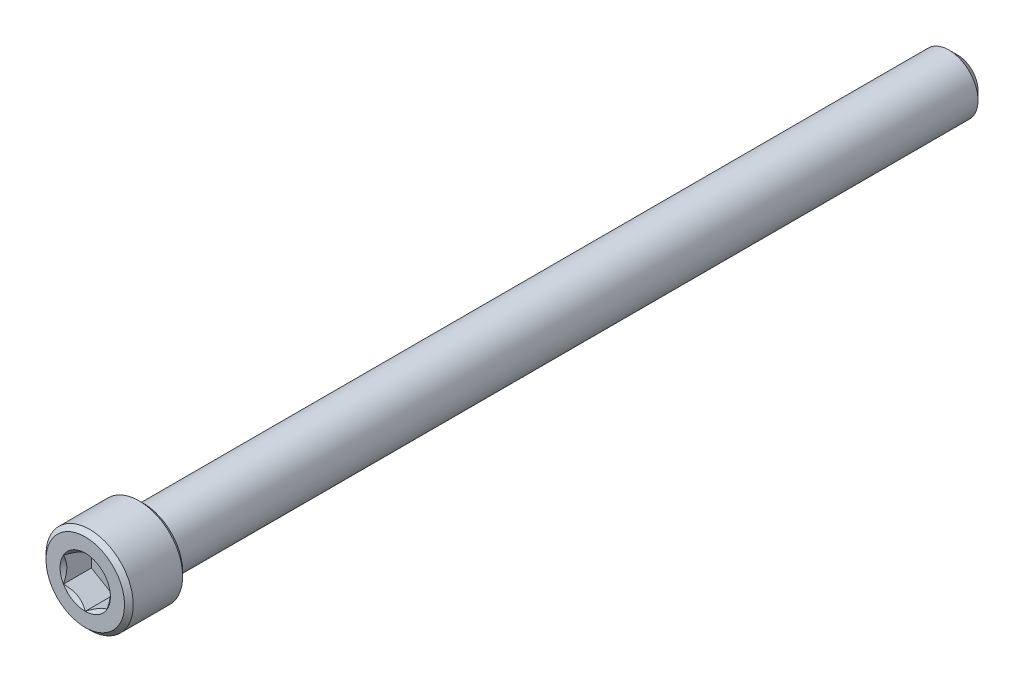
from build123d import *

# Parameters (mm, degrees)
CUT_EXTRUDE1_DEPTH = 3.048
SKETCH5_R          = 2.749630657
CUT_EXTRUDE2_DEPTH = 3.048
CUT_EXTRUDE2_DRAFT = -45
CHAMFER1_SIZE      = 0.47625


with BuildPart() as part:
    # Sketch3 → Revolve1 (revolve)
    with BuildSketch(Plane(origin=(0, 0, 0), x_dir=(0, 0, -1), z_dir=(1, 0, 0))):
        Polygon((-47.625, 4.7625), (-47.625, 2.38125), (-44.577, 2.38125), (-44.577, 0), (47.625, 0), (47.625, 2.2225), (46.6725, 3.175), (-41.275, 3.175), (-41.275, 4.7625), align=None)
    revolve(axis=Axis((0, 0, 47.625), (0, 0, -1)))

    # Sketch4 → Cut-Extrude1 (cut)
    with BuildSketch(Plane.XY.offset(47.625)):
        Polygon((0, 2.749630657), (-2.38125, 1.374815329), (-2.38125, -1.374815329), (0, -2.749630657), (2.38125, -1.374815329), (2.38125, 1.374815329), align=None)
    extrude(amount=-CUT_EXTRUDE1_DEPTH, mode=Mode.SUBTRACT)


with BuildPart() as cut_extrude2_tool:
    # Sketch5 → Cut-Extrude2 (with draft: the straight prism first)
    with BuildSketch(Plane.XY.offset(47.625)):
        Circle(SKETCH5_R)
    extrude(amount=-CUT_EXTRUDE2_DEPTH)
    # Cut-Extrude2: the draft: its side faces are tilted about the plane it starts from
    cut_extrude2_sides = [cut_extrude2_tool.faces().sort_by_distance(p)[0] for p in [
        (-2.749630657, 0, 46.101),
    ]]
    draft(cut_extrude2_sides, Plane.XY.offset(47.625), CUT_EXTRUDE2_DRAFT)


with BuildPart() as part_1:
    add(part.part)

    # Cut-Extrude2: cut by cut_extrude2_tool
    add(cut_extrude2_tool.part, mode=Mode.SUBTRACT)

    # Chamfer1
    chamfer1_edges = [part_1.edges().sort_by_distance(p)[0] for p in [
        (0, -4.7625, 47.625),
        (0, -4.7625, 41.275),
    ]]
    chamfer(chamfer1_edges, length=CHAMFER1_SIZE)


solid = part_1.part
